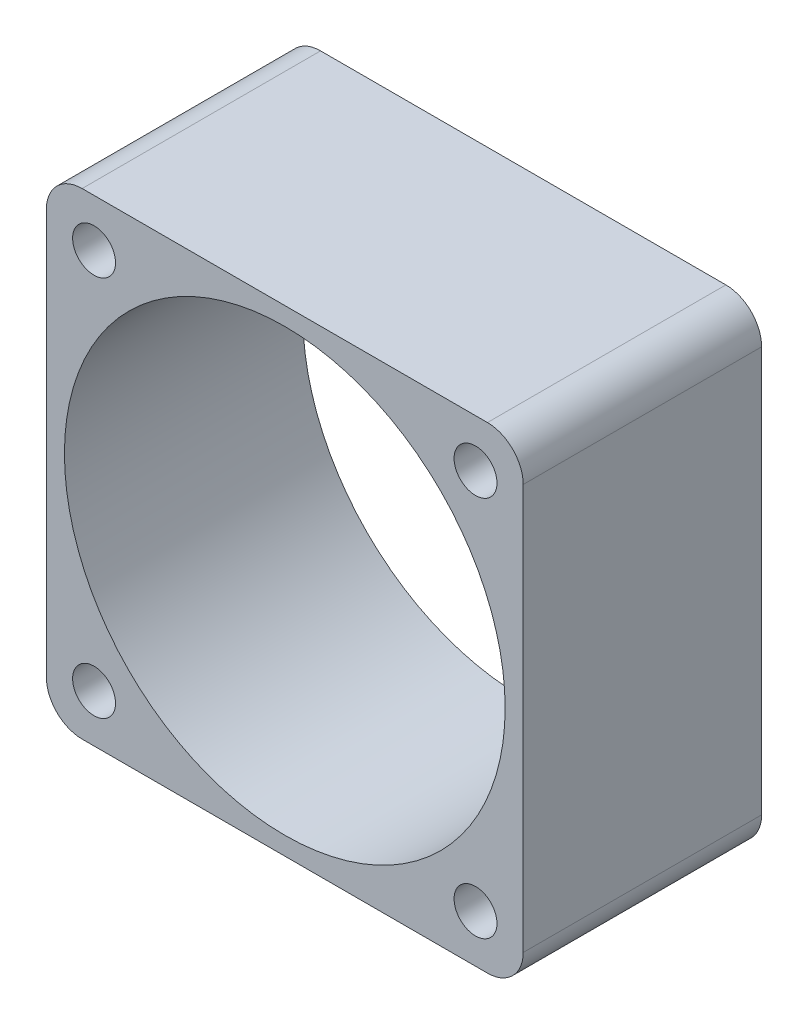
from build123d import *

# Parameters (mm, degrees)
SKETCH1_W           = 40
SKETCH1_H           = 40
SKETCH1_R           = 1.8
SKETCH1_R_2         = 18.484463189
BOSS_EXTRUDE1_DEPTH = 20
FILLET1_R           = 3


with BuildPart() as part:
    # Sketch1 → Boss-Extrude1 (new body)
    with BuildSketch(Plane.XY):
        Rectangle(SKETCH1_W, SKETCH1_H)
        with Locations((-16, 16)):
            Circle(SKETCH1_R, mode=Mode.SUBTRACT)
        with Locations((16, 16)):
            Circle(SKETCH1_R, mode=Mode.SUBTRACT)
        with Locations((16, -16)):
            Circle(SKETCH1_R, mode=Mode.SUBTRACT)
        with Locations((-16, -16)):
            Circle(SKETCH1_R, mode=Mode.SUBTRACT)
        Circle(SKETCH1_R_2, mode=Mode.SUBTRACT)
    extrude(amount=BOSS_EXTRUDE1_DEPTH)

    # Fillet1
    fillet1_edges = [part.edges().sort_by_distance(p)[0] for p in [
        (20, -20, 10),
        (-20, -20, 10),
        (-20, 20, 10),
        (20, 20, 10),
    ]]
    fillet(fillet1_edges, radius=FILLET1_R)


solid = part.part
